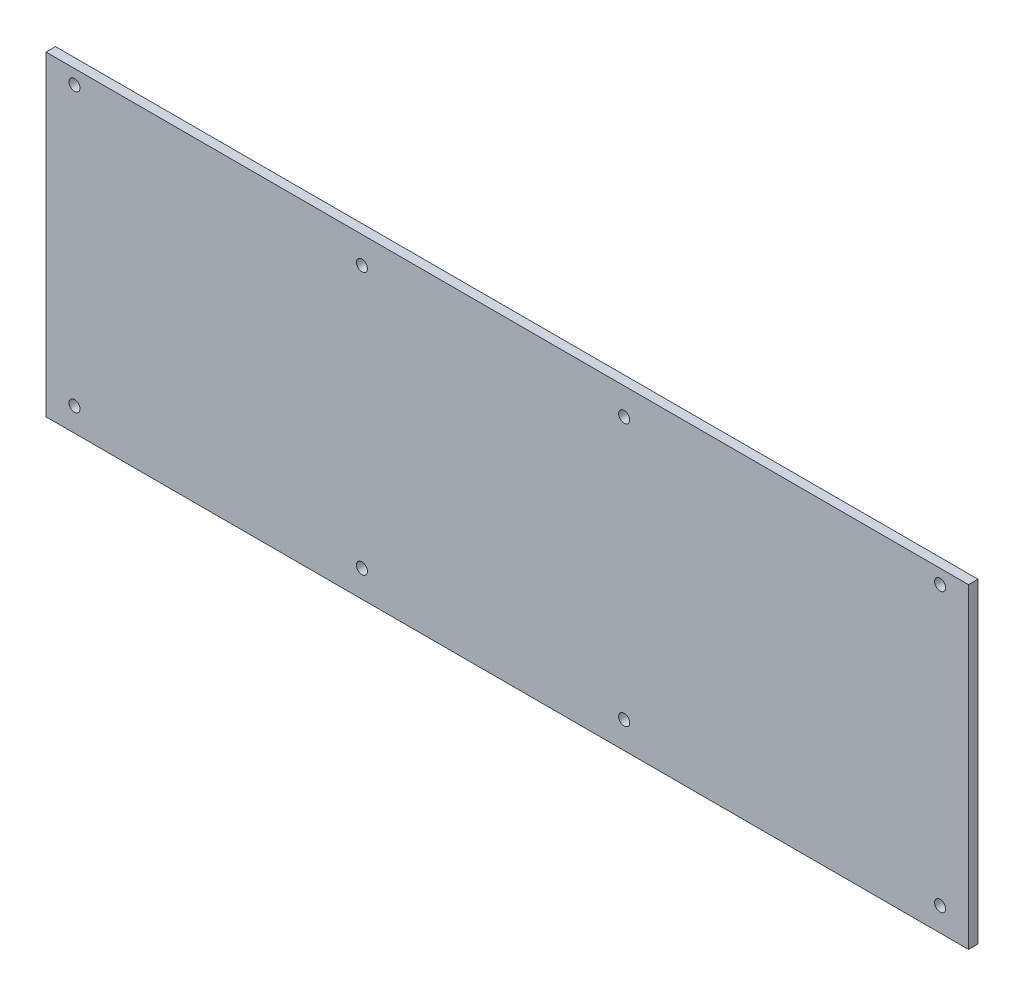
from build123d import *

# Parameters (mm, degrees)
SKETCH1_W           = 300
SKETCH1_H           = 100
BOSS_EXTRUDE1_DEPTH = 3
SKETCH3_W           = 8
SKETCH3_H           = 100
CUT_EXTRUDE2_DEPTH  = 10
SKETCH4_R           = 1.75
CUT_EXTRUDE3_DEPTH  = 4
SKETCH7_R           = 1.75
CUT_EXTRUDE6_DEPTH  = 4


with BuildPart() as part:
    # Sketch1 → Boss-Extrude1 (new body)
    with BuildSketch(Plane.XY):
        with Locations((150, 50)):
            Rectangle(SKETCH1_W, SKETCH1_H)
    extrude(amount=BOSS_EXTRUDE1_DEPTH)

    # Sketch3 → Cut-Extrude2 (cut)
    with BuildSketch(Plane(origin=(0, 0, 0), x_dir=(-1, 0, 0), z_dir=(0, 0, -1))):
        with Locations((-4, 50)):
            Rectangle(SKETCH3_W, SKETCH3_H)
    extrude(amount=-CUT_EXTRUDE2_DEPTH, mode=Mode.SUBTRACT)

    # Sketch4 → Cut-Extrude3 (cut, through all)
    with BuildSketch(Plane(origin=(0, 0, 0), x_dir=(-1, 0, 0), z_dir=(0, 0, -1))):
        with Locations((-291, 95.5)):
            Circle(SKETCH4_R)
        with Locations((-17, 95.5)):
            Circle(SKETCH4_R)
        with Locations((-17, 7.5)):
            Circle(SKETCH4_R)
        with Locations((-291, 7.5)):
            Circle(SKETCH4_R)
    extrude(amount=-CUT_EXTRUDE3_DEPTH, mode=Mode.SUBTRACT)

    # Sketch7 → Cut-Extrude6 (cut, through all)
    with BuildSketch(Plane(origin=(0, 0, 0), x_dir=(-1, 0, 0), z_dir=(0, 0, -1))):
        with Locations((-108, 91.5)):
            Circle(SKETCH7_R)
        with Locations((-191, 91.5)):
            Circle(SKETCH7_R)
        with Locations((-191, 8.5)):
            Circle(SKETCH7_R)
        with Locations((-108, 8.5)):
            Circle(SKETCH7_R)
    extrude(amount=-CUT_EXTRUDE6_DEPTH, mode=Mode.SUBTRACT)


solid = part.part
